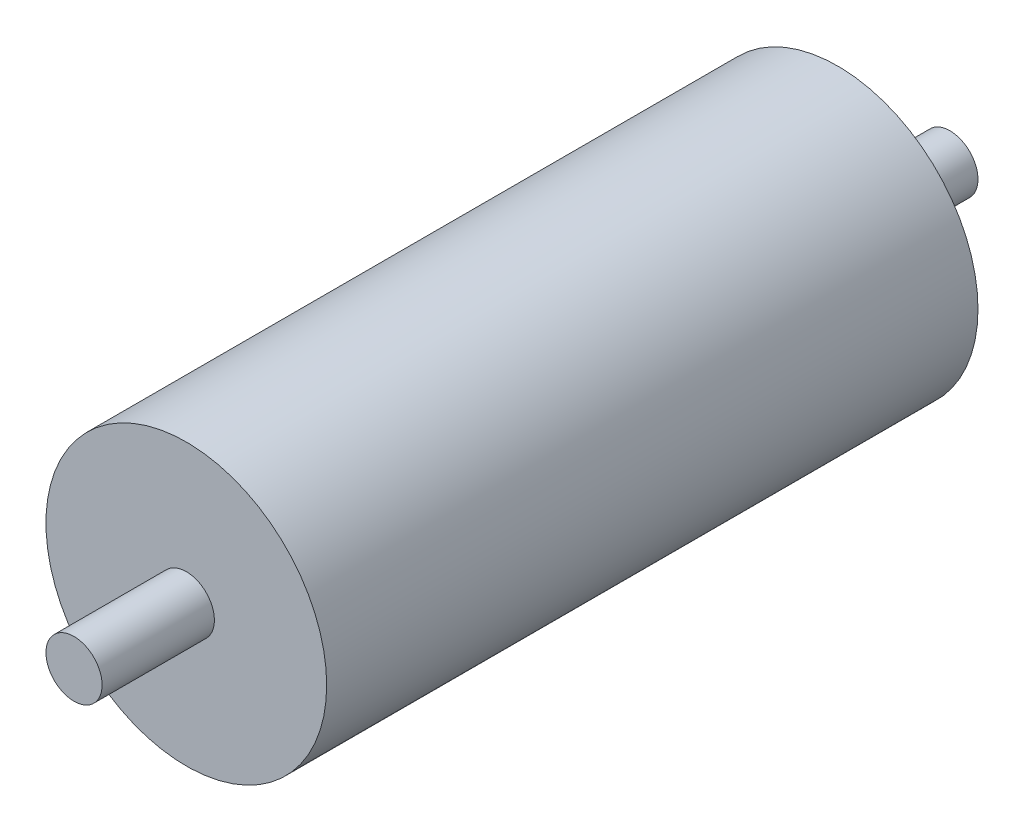
from build123d import *

# Parameters (mm, degrees)
SKETCH1_R           = 12.5
BOSS_EXTRUDE1_DEPTH = 58
SKETCH2_R           = 2.5
BOSS_EXTRUDE2_DEPTH = 10
SKETCH3_R           = 2.5
BOSS_EXTRUDE3_DEPTH = 10


with BuildPart() as part:
    # Sketch1 → Boss-Extrude1 (new body)
    with BuildSketch(Plane.XY):
        Circle(SKETCH1_R)
    extrude(amount=BOSS_EXTRUDE1_DEPTH)

    # Sketch2 → Boss-Extrude2 (add)
    with BuildSketch(Plane.XY.offset(58)):
        Circle(SKETCH2_R)
    extrude(amount=BOSS_EXTRUDE2_DEPTH)

    # Sketch3 → Boss-Extrude3 (add)
    with BuildSketch(Plane(origin=(0, 0, 0), x_dir=(-1, 0, 0), z_dir=(0, 0, -1))):
        Circle(SKETCH3_R)
    extrude(amount=BOSS_EXTRUDE3_DEPTH)


solid = part.part
